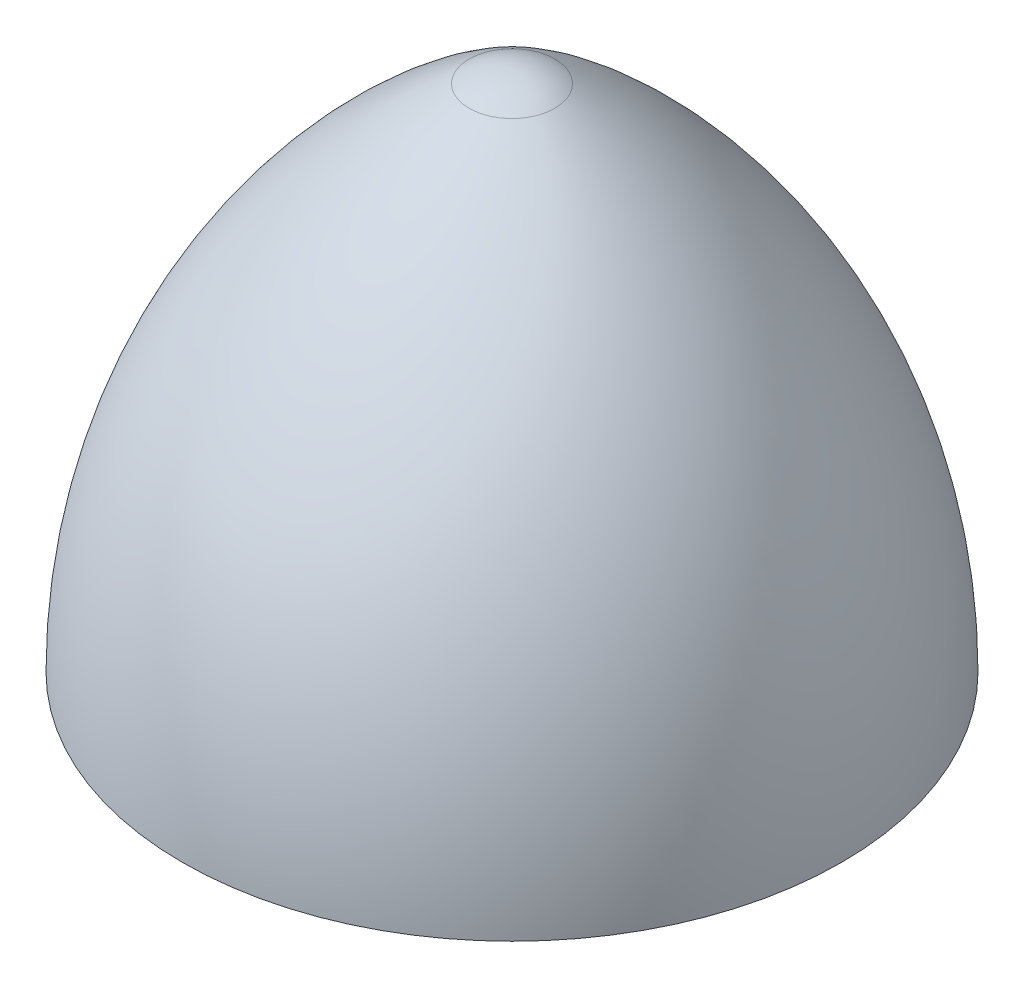
from build123d import *

# Parameters (mm, degrees)
F_1_2_20_TAPPED_HOLE1_D     = 11.50874
F_1_2_20_TAPPED_HOLE1_DEPTH = 16.51
F_1_2_20_TAPPED_HOLE1_TIP   = 3.45757432


with BuildPart() as part:
    # Sketch1 → Revolve3 (revolve)
    with BuildSketch(Plane.XY):
        with BuildLine():
            Line((0, -25.4), (19.05, -25.4))
            ThreePointArc((19.05, -25.4), (14.621407255, -8.493817794), (2.473108309, 4.070029674))
            ThreePointArc((2.473108309, 4.070029674), (1.28411252, 4.586116144), (0, 4.7625))
            Line((0, 4.7625), (0, -25.4))
        make_face()
    revolve(axis=Axis((0, -25.4, 0), (0, 1, 0)))

    # 1/2-20 Tapped Hole1
    with Locations(Plane(origin=(0, -25.4, 0), x_dir=(-1, 0, 0), z_dir=(0, -1, 0))):
        with Locations((0, 0)):
            Hole(F_1_2_20_TAPPED_HOLE1_D / 2, depth=F_1_2_20_TAPPED_HOLE1_DEPTH)
            with Locations((0, 0, -(F_1_2_20_TAPPED_HOLE1_DEPTH + F_1_2_20_TAPPED_HOLE1_TIP / 2))):  # 118° drill point
                Cone(0, F_1_2_20_TAPPED_HOLE1_D / 2, F_1_2_20_TAPPED_HOLE1_TIP, mode=Mode.SUBTRACT)


solid = part.part
